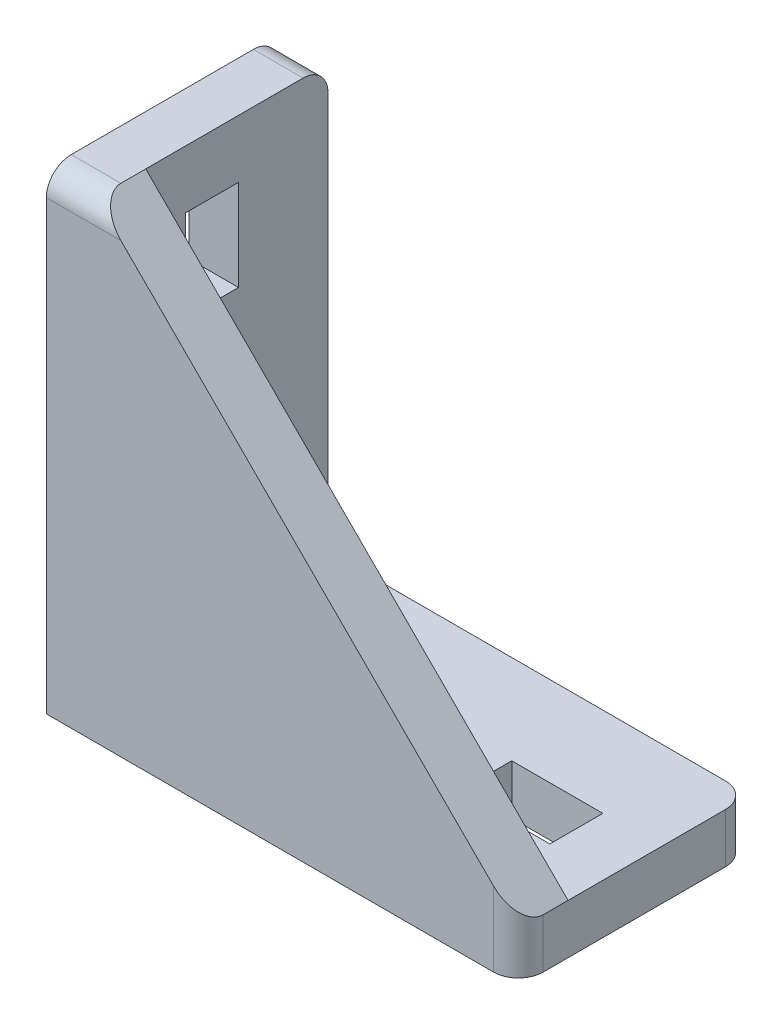
from build123d import *

# Parameters (mm, degrees)
AUFSATZ_LINEAR_AUSTRAGEN1_DEPTH = 28
AUFSATZ_LINEAR_AUSTRAGEN2_DEPTH = 6
SKIZZE3_W                       = 6.4
SKIZZE3_H                       = 11
SKIZZE3_H_2                     = 10
SCHNITT_LINEAR_AUSTRAGEN1_DEPTH = 7
SKIZZE4_W                       = 11
SKIZZE4_H                       = 6.4
SKIZZE4_W_2                     = 10
SCHNITT_LINEAR_AUSTRAGEN2_DEPTH = 7
VERRUNDUNG1_R                   = 3


with BuildPart() as part:
    # Skizze1 → Aufsatz-Linear austragen1 (new body)
    with BuildSketch(Plane.XY):
        Polygon((0, 0), (0, 57), (6, 57), (6, 6), (57, 6), (57, 0), align=None)
    extrude(amount=AUFSATZ_LINEAR_AUSTRAGEN1_DEPTH)

    # Skizze2 → Aufsatz-Linear austragen2 (add)
    with BuildSketch(Plane.XY.offset(28)):
        Polygon((6, 57), (6, 6), (57, 6), align=None)
    extrude(amount=-AUFSATZ_LINEAR_AUSTRAGEN2_DEPTH)

    # Skizze3 → Schnitt-Linear austragen1 (cut, through all)
    with BuildSketch(Plane(origin=(6, 0, 0), x_dir=(0, 0, -1), z_dir=(1, 0, 0))):
        with Locations((-14, 44.5)):
            Rectangle(SKIZZE3_W, SKIZZE3_H)
        with Locations((-14, 15)):
            Rectangle(SKIZZE3_W, SKIZZE3_H_2)
    extrude(amount=-SCHNITT_LINEAR_AUSTRAGEN1_DEPTH, mode=Mode.SUBTRACT)

    # Skizze4 → Schnitt-Linear austragen2 (cut, through all)
    with BuildSketch(Plane(origin=(0, 6, 0), x_dir=(1, 0, 0), z_dir=(0, 1, 0))):
        with Locations((44.5, -14)):
            Rectangle(SKIZZE4_W, SKIZZE4_H)
        with Locations((15, -14)):
            Rectangle(SKIZZE4_W_2, SKIZZE4_H)
    extrude(amount=-SCHNITT_LINEAR_AUSTRAGEN2_DEPTH, mode=Mode.SUBTRACT)

    # Verrundung1
    verrundung1_edges = [part.edges().sort_by_distance(p)[0] for p in [
        (3, 57, 28),
        (3, 57, 0),
        (57, 3, 28),
        (57, 3, 0),
    ]]
    fillet(verrundung1_edges, radius=VERRUNDUNG1_R)


solid = part.part
